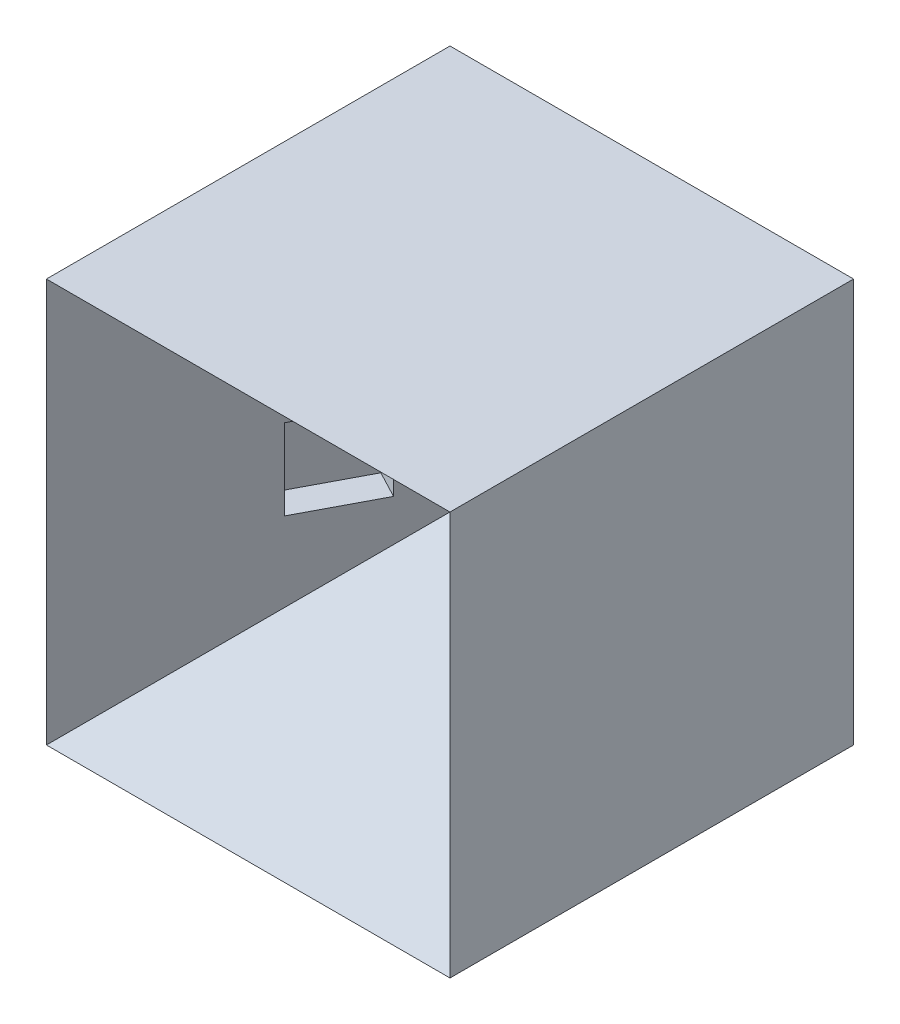
from build123d import *

# Parameters (mm, degrees)
SKETCH1_W           = 20
SKETCH1_H           = 20
BOSS_EXTRUDE1_DEPTH = 20
SKETCH7_W           = 4
SKETCH7_H           = 4
CUT_EXTRUDE2_DEPTH  = 1.5
SCALE1_SCALE        = 2


with BuildPart() as part:
    # Sketch1 → Boss-Extrude1 (new body)
    with BuildSketch(Plane.XY):
        Rectangle(SKETCH1_W, SKETCH1_H)
    extrude(amount=BOSS_EXTRUDE1_DEPTH)

    # Sketch6 → entrada furo section 0
    with BuildSketch(Plane.XY.offset(20), mode=Mode.PRIVATE) as entrada_furo_s0:
        with BuildLine():
            Line((-10, 10), (-10, -10))
            Line((-10, -10), (10, -10))
            Line((10, -10), (10, 10))
            Line((10, 10), (-10, 10))
        make_face()
    loft([entrada_furo_s0.sketch, Vertex(0, 0, 1)], mode=Mode.SUBTRACT)

    # Sketch7 → Cut-Extrude2 (cut)
    with BuildSketch(Plane(origin=(0.412147505, 0, 0.21691974), x_dir=(0.46574643283262235, 0, -0.8849182223819824), z_dir=(0.8849182223819824, 0, 0.46574643283262235))):
        with Locations((-11.620373499, 0)):
            Rectangle(SKETCH7_W, SKETCH7_H)
    cut_extrude2 = extrude(amount=-CUT_EXTRUDE2_DEPTH, mode=Mode.SUBTRACT)

    # Mirror1: Cut-Extrude2 across plane
    add(cut_extrude2.mirror(Plane(origin=(0, 0, 0), x_dir=(0, 0, 1), z_dir=(1, 0, 0))), mode=Mode.SUBTRACT)


with BuildPart() as part_1:
    # Scale1: scaled about (0, 0, 7.5441868)
    add(part.part.scale(SCALE1_SCALE).moved(Location((0, 0, -7.5441868))))


solid = part_1.part
